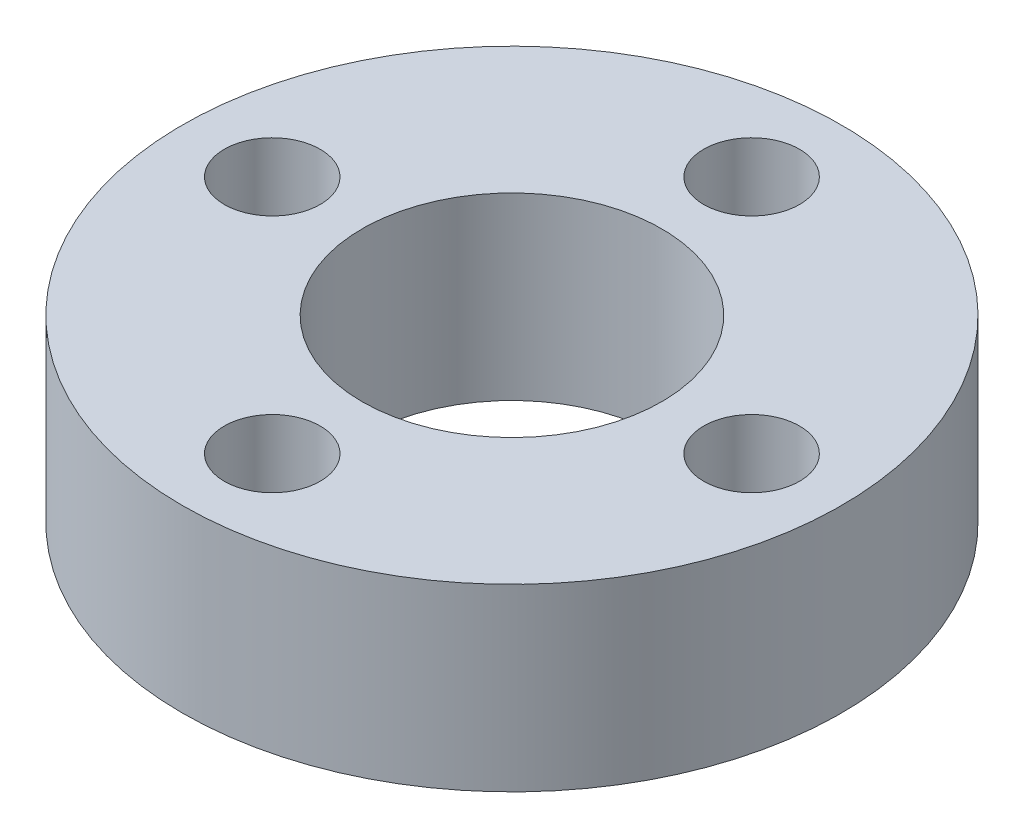
from build123d import *

# Parameters (mm, degrees)
SKETCH1_R           = 27.5
SKETCH1_R_2         = 12.5
SKETCH1_R_3         = 4
BOSS_EXTRUDE1_DEPTH = 15


with BuildPart() as part:
    # Sketch1 → Boss-Extrude1 (new body)
    with BuildSketch(Plane(origin=(0, 0, 0), x_dir=(1, 0, 0), z_dir=(0, 1, 0))):
        Circle(SKETCH1_R)
        Circle(SKETCH1_R_2, mode=Mode.SUBTRACT)
        with Locations((0, 20)):
            Circle(SKETCH1_R_3, mode=Mode.SUBTRACT)
        with Locations((20, 0)):
            Circle(SKETCH1_R_3, mode=Mode.SUBTRACT)
        with Locations((0, -20)):
            Circle(SKETCH1_R_3, mode=Mode.SUBTRACT)
        with Locations((-20, 0)):
            Circle(SKETCH1_R_3, mode=Mode.SUBTRACT)
    extrude(amount=BOSS_EXTRUDE1_DEPTH)


solid = part.part
